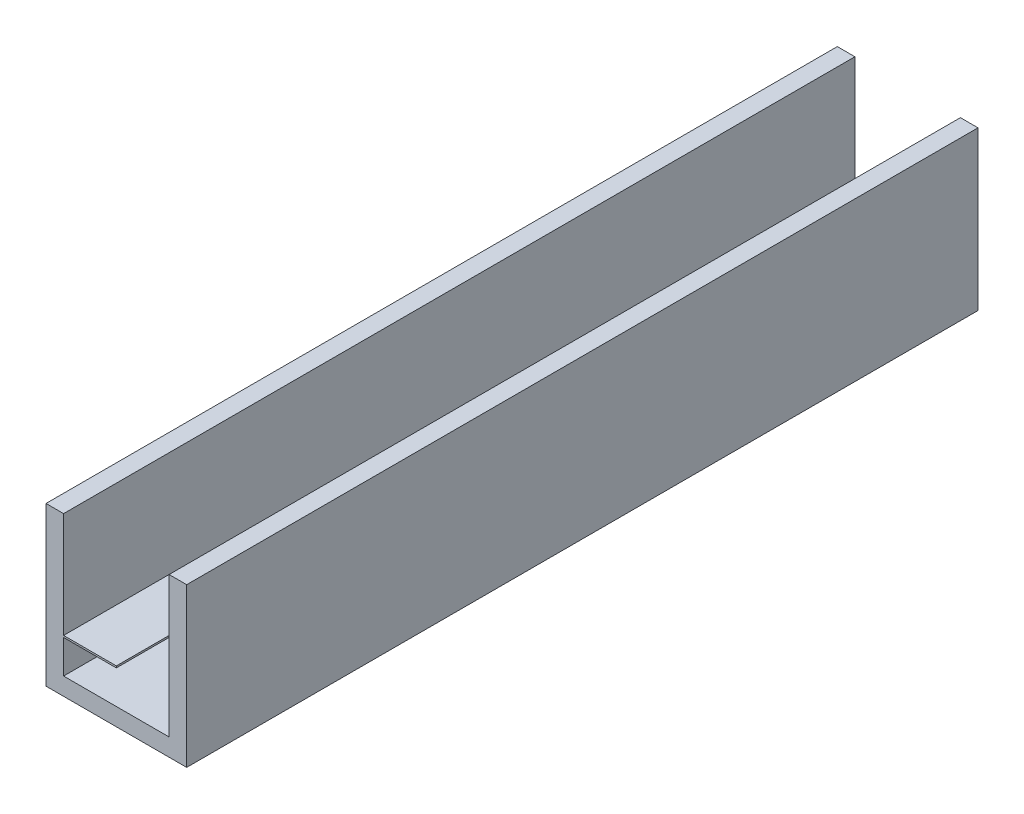
from build123d import *

# Parameters (mm, degrees)
SALIENTE_EXTRUIR1_DEPTH = 4500
CROQUIS2_W              = 300
CROQUIS2_H              = 10
SALIENTE_EXTRUIR2_DEPTH = 4500


with BuildPart() as part:
    # Croquis1 → Saliente-Extruir1 (new body)
    with BuildSketch(Plane.XY):
        Polygon((0, 0), (-800, 0), (-800, 900), (-700, 900), (-700, 100), (-100, 100), (-100, 900), (0, 900), align=None)
    extrude(amount=SALIENTE_EXTRUIR1_DEPTH)

    # Croquis2 → Saliente-Extruir2 (add)
    with BuildSketch(Plane(origin=(0, 0, 0), x_dir=(-1, 0, 0), z_dir=(0, 0, -1))):
        with Locations((550, 295)):
            Rectangle(CROQUIS2_W, CROQUIS2_H)
    extrude(amount=-SALIENTE_EXTRUIR2_DEPTH)


solid = part.part
